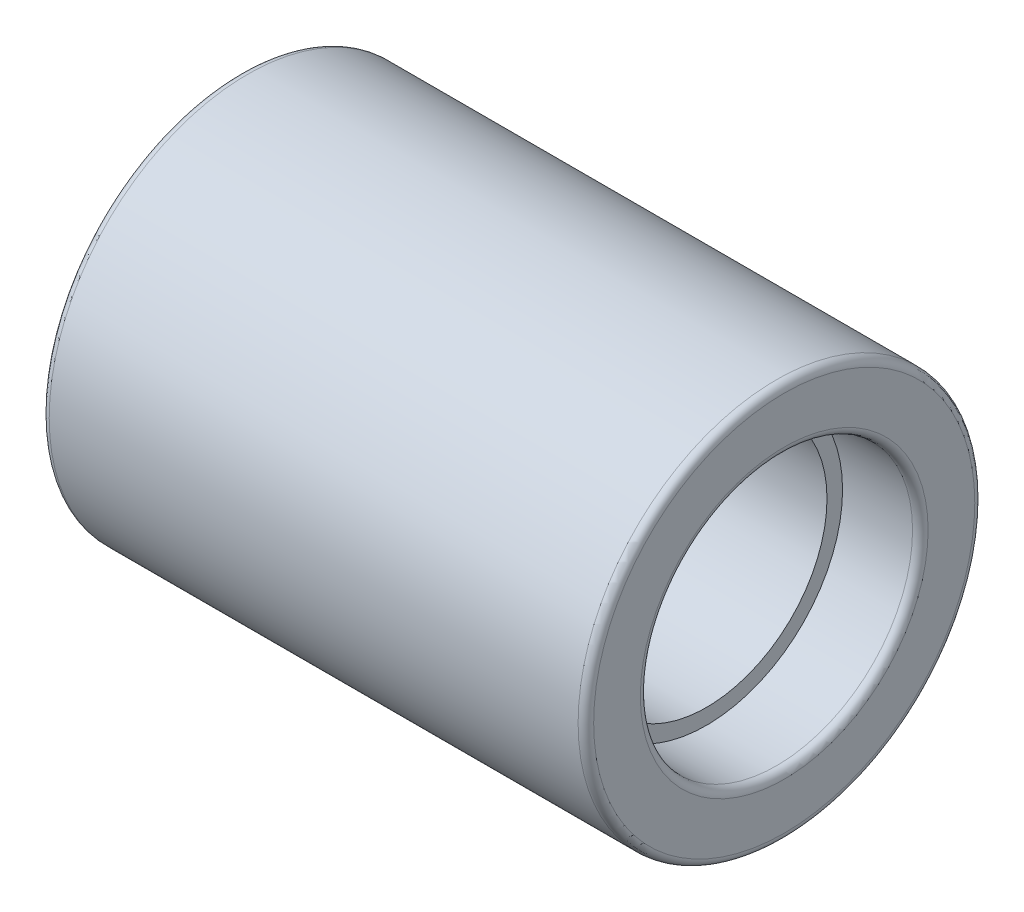
from build123d import *

# Parameters (mm, degrees)
SKETCH2_R           = 25.5
SKETCH2_R_2         = 15.5
BOSS_EXTRUDE1_DEPTH = 70
SKETCH3_R           = 17.5
CUT_EXTRUDE1_DEPTH  = 10
SKETCH4_R           = 17.5
CUT_EXTRUDE2_DEPTH  = 10
FILLET1_R           = 1


with BuildPart() as part:
    # Sketch2 → Boss-Extrude1 (new body)
    with BuildSketch(Plane(origin=(0, 0, 0), x_dir=(0, 0, -1), z_dir=(1, 0, 0))):
        Circle(SKETCH2_R)
        Circle(SKETCH2_R_2, mode=Mode.SUBTRACT)
    extrude(amount=BOSS_EXTRUDE1_DEPTH)

    # Sketch3 → Cut-Extrude1 (cut)
    with BuildSketch(Plane(origin=(70, 0, 0), x_dir=(0, 0, -1), z_dir=(1, 0, 0))):
        Circle(SKETCH3_R)
    extrude(amount=-CUT_EXTRUDE1_DEPTH, mode=Mode.SUBTRACT)

    # Sketch4 → Cut-Extrude2 (cut)
    with BuildSketch(Plane.ZY):
        Circle(SKETCH4_R)
    extrude(amount=-CUT_EXTRUDE2_DEPTH, mode=Mode.SUBTRACT)

    # Fillet1
    fillet1_edges = [part.edges().sort_by_distance(p)[0] for p in [
        (70, 0, 17.5),
        (0, 0, -17.5),
        (0, 0, 25.5),
        (70, 0, 25.5),
    ]]
    fillet(fillet1_edges, radius=FILLET1_R)


solid = part.part
